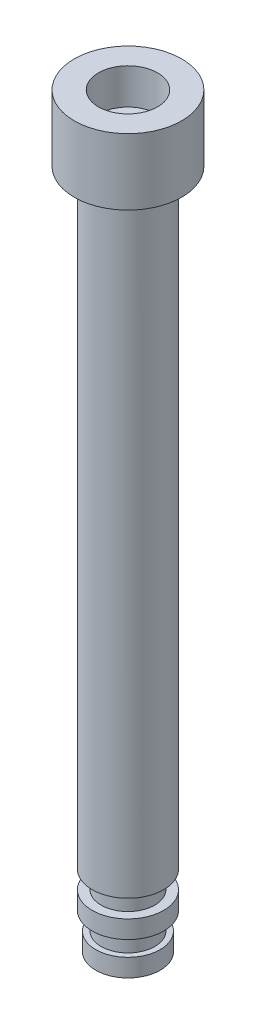
from build123d import *

# Parameters (mm, degrees)
SKETCH1_R           = 3
BOSS_EXTRUDE1_DEPTH = 3.7
SKETCH1_3_R         = 1.6
BOSS_EXTRUDE2_DEPTH = 1
SKETCH5_R           = 1.5
BOSS_EXTRUDE3_DEPTH = 35
SKETCH6_R           = 2
BOSS_EXTRUDE4_DEPTH = 1
SKETCH8_R           = 1.5
BOSS_EXTRUDE5_DEPTH = 2
SKETCH10_R          = 1.8
BOSS_EXTRUDE6_DEPTH = 1
SKETCH12_R          = 1.65
CUT_EXTRUDE1_DEPTH  = 2
SKETCH13_R          = 2
BOSS_EXTRUDE7_DEPTH = 34


with BuildPart() as part:
    # Sketch1 → Boss-Extrude1 (new body)
    with BuildSketch(Plane(origin=(0, 0, 0), x_dir=(1, 0, 0), z_dir=(0, 1, 0))):
        with Locations((-0.522013312, 0.511138034)):
            Circle(SKETCH1_R)
    extrude(amount=BOSS_EXTRUDE1_DEPTH)

    # Sketch1_3 → Boss-Extrude2 (add)
    with BuildSketch(Plane(origin=(0, 0, 0), x_dir=(1, 0, 0), z_dir=(0, 1, 0))):
        with Locations((-0.522013312, 0.511138034)):
            Circle(SKETCH1_3_R)
    extrude(amount=BOSS_EXTRUDE2_DEPTH)

    # Sketch5 → Boss-Extrude3 (add)
    with BuildSketch(Plane.XZ):
        with Locations((-0.522013312, -0.511138034)):
            Circle(SKETCH5_R)
    extrude(amount=BOSS_EXTRUDE3_DEPTH)

    # Sketch6 → Boss-Extrude4 (add)
    with BuildSketch(Plane.XZ.offset(35)):
        with Locations((-0.522013312, -0.511138034)):
            Circle(SKETCH6_R)
    extrude(amount=BOSS_EXTRUDE4_DEPTH)

    # Sketch8 → Boss-Extrude5 (add)
    with BuildSketch(Plane(origin=(0, -36, 0), x_dir=(-1, 0, 0), z_dir=(0, -1, 0))):
        with Locations((0.522013312, 0.511138034)):
            Circle(SKETCH8_R)
    extrude(amount=BOSS_EXTRUDE5_DEPTH)

    # Sketch10 → Boss-Extrude6 (add)
    with BuildSketch(Plane.XZ.offset(38)):
        with Locations((-0.522013312, -0.511138034)):
            Circle(SKETCH10_R)
    extrude(amount=-BOSS_EXTRUDE6_DEPTH)

    # Sketch12 → Cut-Extrude1 (cut)
    with BuildSketch(Plane(origin=(0, 3.7, 0), x_dir=(1, 0, 0), z_dir=(0, 1, 0))):
        with Locations((-0.522013312, 0.511138034)):
            Circle(SKETCH12_R)
    extrude(amount=-CUT_EXTRUDE1_DEPTH, mode=Mode.SUBTRACT)

    # Sketch13 → Boss-Extrude7 (add)
    with BuildSketch(Plane.XZ):
        with Locations((-0.522013312, -0.511138034)):
            Circle(SKETCH13_R)
    extrude(amount=BOSS_EXTRUDE7_DEPTH)


solid = part.part
